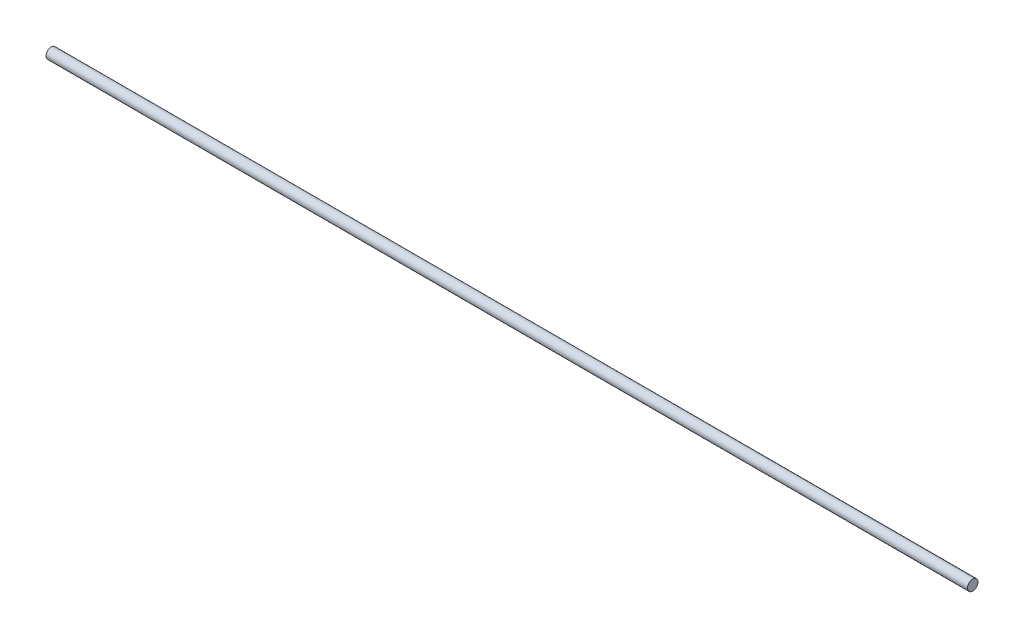
from build123d import *

# Parameters (mm, degrees)
BARRER1_PROFILE_R = 3.125


with BuildPart() as part:
    # Barrer1: sweep along a path in Croquis1
    with BuildLine(Plane.XY) as barrer1_path:
        Line((0, 0), (550, 0))
    # Barrer1 profile (on start of the path) → Barrer1 (sweep)
    with BuildSketch(Plane(origin=(0, 0, 0), x_dir=(0, 0, 1), z_dir=(1, 0, 0))):
        Circle(BARRER1_PROFILE_R)
    sweep(path=barrer1_path.line)


solid = part.part
